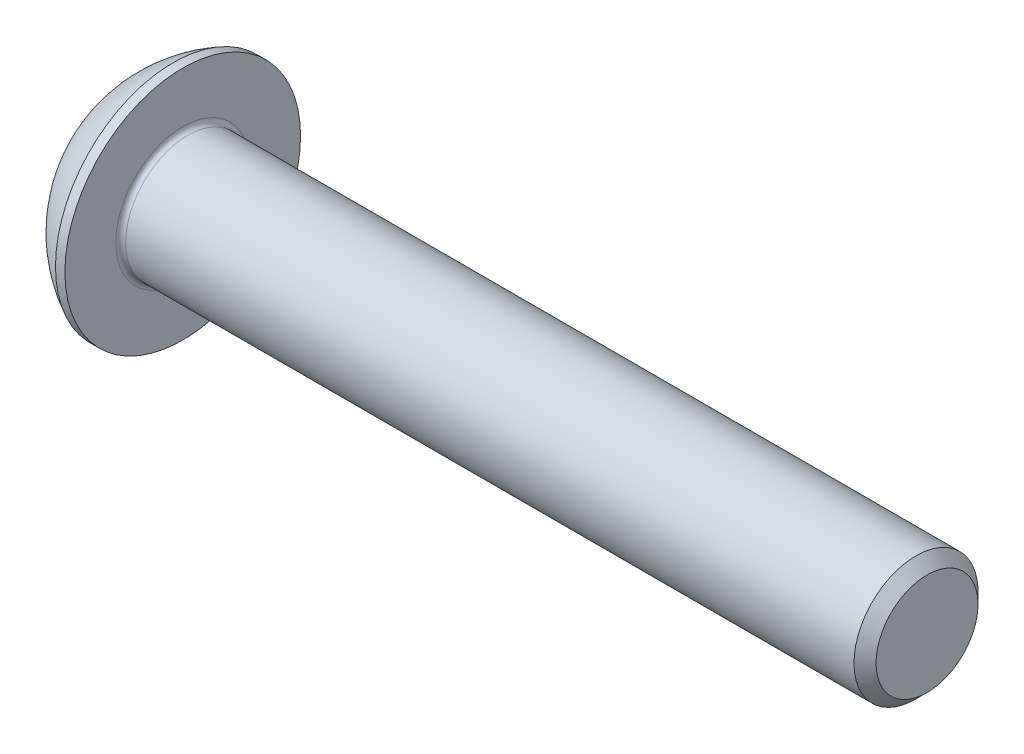
from build123d import *

# Parameters (mm, degrees)
FILLET1_R   = 0.2
HEX_2_DEPTH = 1.56


with BuildPart() as part:
    # BodySke → BaseBody (revolve)
    with BuildSketch(Plane.XY, mode=Mode.PRIVATE) as basebody_sk:
        with BuildLine():
            Line((32.75, 0), (32.75, 2.055))
            Line((32.75, 2.055), (32.305, 2.5))
            Line((32.305, 2.5), (2.75, 2.5))
            Line((2.75, 2.5), (2.75, 4.75))
            Line((2.75, 4.75), (2.37, 4.75))
            ThreePointArc((2.37, 4.75), (0.992680215, 3.754414901), (0, 2.375))
            Line((0, 2.375), (0, 0))
            Line((0, 0), (32.75, 0))
        make_face()
    revolve(basebody_sk.sketch.rotate(Axis((0, 0, 0), (1, 0, 0)), 90), axis=Axis((0, 0, 0), (1, 0, 0)))  # turned: the seam where the file's is

    # Fillet1
    fillet1_edges = [part.edges().sort_by_distance(p)[0] for p in [
        (2.75, 0, -2.5),
    ]]
    fillet(fillet1_edges, radius=FILLET1_R)

    # Sketch2 → PreBroach (revolve, cut)
    with BuildSketch(Plane.XY, mode=Mode.PRIVATE) as prebroach_sk:
        Polygon((0, 1.5), (1.56, 1.5), (2.426025404, 0), (0, 0), align=None)
    revolve(prebroach_sk.sketch.rotate(Axis((0, 0, 0), (1, 0, 0)), 90), axis=Axis((0, 0, 0), (1, 0, 0)), mode=Mode.SUBTRACT)  # turned: the seam where the file's is

    # Sketch3 → Hex 2 (cut)
    with BuildSketch(Plane(origin=(0, 0, 0), x_dir=(0, 0, -1), z_dir=(1, 0, 0))):
        Polygon((-1.5, -0.866025404), (-1.5, 0.866025404), (0, 1.732050808), (1.5, 0.866025404), (1.5, -0.866025404), (0, -1.732050808), align=None)
    extrude(amount=HEX_2_DEPTH, mode=Mode.SUBTRACT)


solid = part.part
